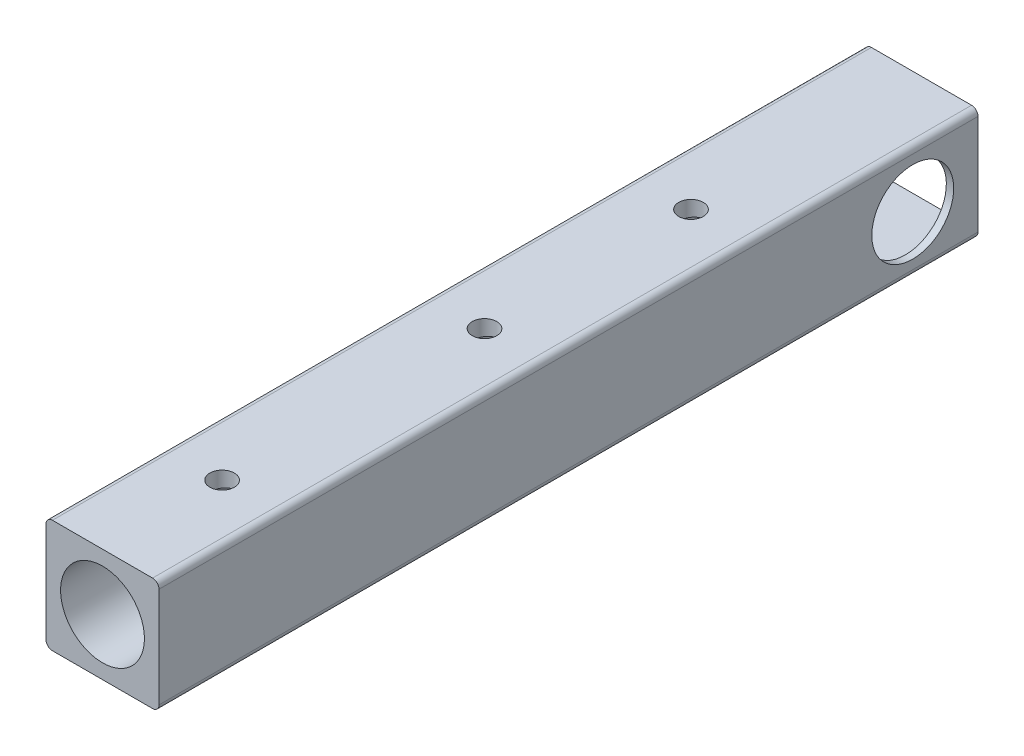
from build123d import *

# Parameters (mm, degrees)
SKETCH1_W           = 35.052
SKETCH1_H           = 35.052
SKETCH1_W_2         = 30.48
SKETCH1_H_2         = 30.48
BOSS_EXTRUDE1_DEPTH = 254
FILLET1_R           = 2
FILLET2_R           = 2
SKETCH2_R           = 12.7
CUT_EXTRUDE1_DEPTH  = 254
SKETCH3_R           = 3.81
CUT_EXTRUDE2_DEPTH  = 254
BOSS_EXTRUDE3_REACH = 37.052
SKETCH4_W           = 31.052
SKETCH4_H           = 5.462350323
SKETCH6_W           = 30.48
SKETCH6_H           = 30.48
SKETCH6_R           = 13
BOSS_EXTRUDE4_DEPTH = 217.402
SKETCH7_R           = 3.81
CUT_EXTRUDE3_DEPTH  = 217.402


with BuildPart() as part:
    # Sketch1 → Boss-Extrude1 (new body)
    with BuildSketch(Plane.XY):
        Rectangle(SKETCH1_W, SKETCH1_H)
        Rectangle(SKETCH1_W_2, SKETCH1_H_2, mode=Mode.SUBTRACT)
    extrude(amount=BOSS_EXTRUDE1_DEPTH)

    # Fillet1
    fillet1_edges = [part.edges().sort_by_distance(p)[0] for p in [
        (17.526, -17.526, 127),
        (-17.526, -17.526, 127),
        (-17.526, 17.526, 127),
        (17.526, 17.526, 127),
    ]]
    fillet(fillet1_edges, radius=FILLET1_R)

    # Fillet2
    fillet2_edges = [part.edges().sort_by_distance(p)[0] for p in [
        (15.24, -15.24, 127),
        (15.24, 15.24, 127),
        (-15.24, 15.24, 127),
        (-15.24, -15.24, 127),
    ]]
    fillet(fillet2_edges, radius=FILLET2_R)

    # Sketch2 → Cut-Extrude1 (cut)
    with BuildSketch(Plane.ZY.offset(17.526)):
        with Locations((20.234414068, 0)):
            Circle(SKETCH2_R)
    extrude(amount=-CUT_EXTRUDE1_DEPTH, mode=Mode.SUBTRACT)

    # Sketch3 → Cut-Extrude2 (cut)
    with BuildSketch(Plane(origin=(0, 17.526, 0), x_dir=(1, 0, 0), z_dir=(0, 1, 0))):
        with Locations((0, -135.527156181)):
            Circle(SKETCH3_R)
        with Locations((0, -216.910746369)):
            Circle(SKETCH3_R)
        with Locations((0, -71.490837775)):
            Circle(SKETCH3_R)
    extrude(amount=-CUT_EXTRUDE2_DEPTH, mode=Mode.SUBTRACT)

    # Sketch4 → Boss-Extrude3 (add, up to next)
    with BuildSketch(Plane(origin=(0, 17.526, 0), x_dir=(1, 0, 0), z_dir=(0, 1, 0)), mode=Mode.PRIVATE) as boss_extrude3_sk1:
        with Locations((0, -42.400785955)):
            Rectangle(SKETCH4_W, SKETCH4_H)
    boss_extrude3_tool1 = extrude(boss_extrude3_sk1.sketch, amount=-BOSS_EXTRUDE3_REACH, mode=Mode.PRIVATE) - part.part
    add(boss_extrude3_tool1.solids().sort_by_distance((0, 17.526, 42.400786))[0])

    # Sketch6 → Boss-Extrude4 (add)
    with BuildSketch(Plane.XY.offset(254)):
        Rectangle(SKETCH6_W, SKETCH6_H)
        Circle(SKETCH6_R, mode=Mode.SUBTRACT)
    extrude(amount=-BOSS_EXTRUDE4_DEPTH)

    # Sketch7 → Cut-Extrude3 (cut)
    with BuildSketch(Plane(origin=(0, 17.526, 0), x_dir=(1, 0, 0), z_dir=(0, 1, 0))):
        with Locations((0, -71.490837775)):
            Circle(SKETCH7_R)
        with Locations((0, -135.527156181)):
            Circle(SKETCH7_R)
        with Locations((0, -216.910746369)):
            Circle(SKETCH7_R)
    extrude(amount=-CUT_EXTRUDE3_DEPTH, mode=Mode.SUBTRACT)


solid = part.part
